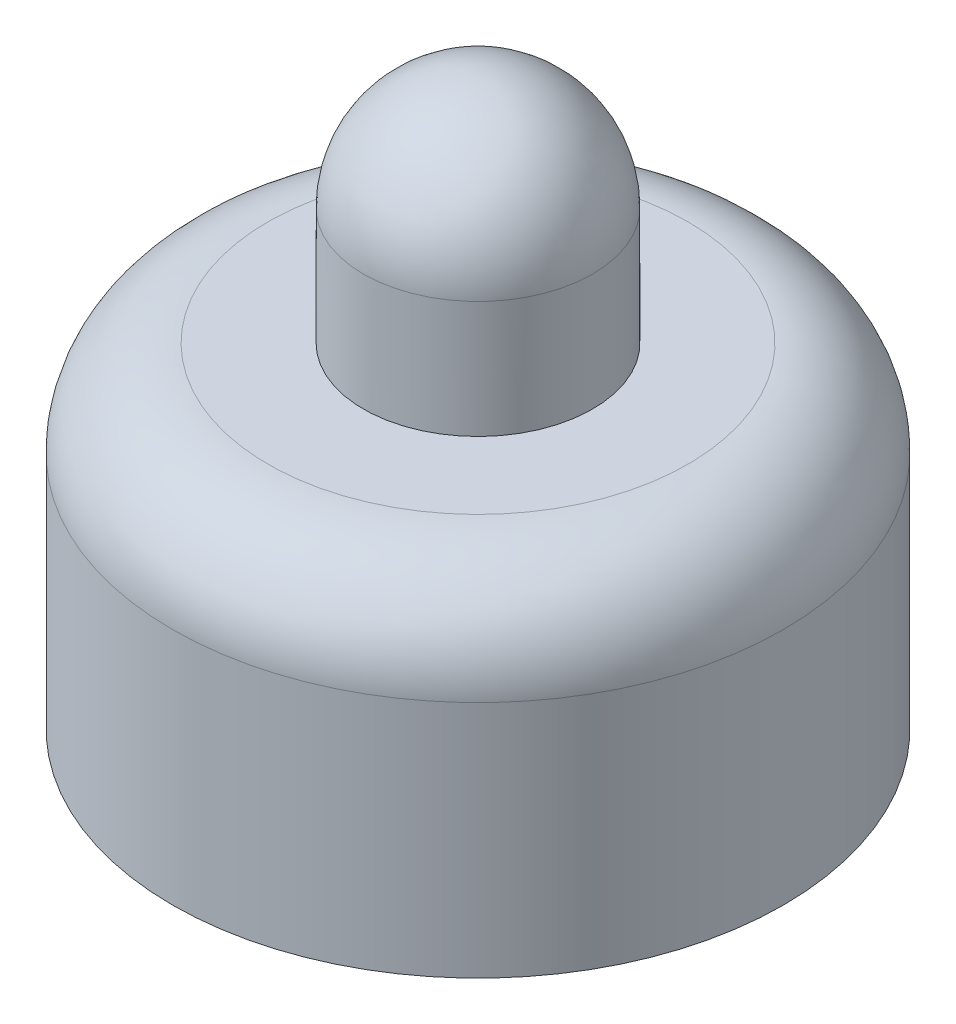
from build123d import *

# Parameters (mm, degrees)
FILLET_1_R = 2


with BuildPart() as part:
    # 草图1 → 旋转1 (revolve)
    with BuildSketch(Plane.XY):
        with BuildLine():
            Line((0, 19.185714286), (0, 7.335714286))
            Line((0, 7.335714286), (6.4, 7.335714286))
            Line((6.4, 7.335714286), (6.4, 14.335714286))
            Line((6.4, 14.335714286), (2.4, 14.335714286))
            Line((2.4, 14.335714286), (2.4, 16.785714286))
            ThreePointArc((2.4, 16.785714286), (1.697056275, 18.482770561), (0, 19.185714286))
        make_face()
    revolve(axis=Axis((0, 0, 0), (0, 1, 0)))

    # 圆角1
    fillet_1_edges = [part.edges().sort_by_distance(p)[0] for p in [
        (-6.4, 14.335714286, 0),
    ]]
    fillet(fillet_1_edges, radius=FILLET_1_R)


solid = part.part
